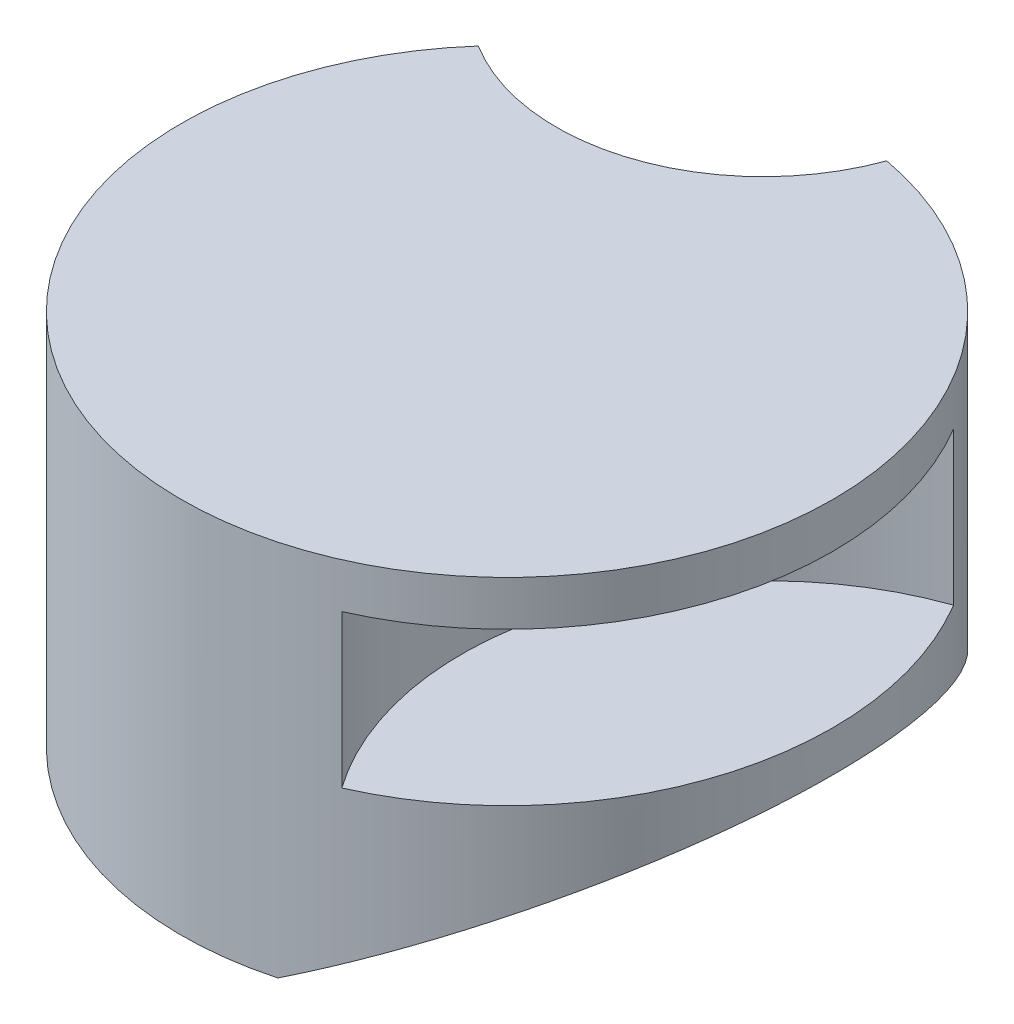
from build123d import *

# Parameters (mm, degrees)
BOSS_EXTRUDE1_DEPTH = 84
CUT_EXTRUDE2_DEPTH  = 34
CUT_EXTRUDE3_DEPTH  = 144.7823905
CUT_EXTRUDE4_DEPTH  = 43


with BuildPart() as part:
    # Sketch1 → Boss-Extrude1 (new body)
    with BuildSketch(Plane(origin=(0, 0, 0), x_dir=(1, 0, 0), z_dir=(0, 1, 0))):
        with BuildLine():
            ThreePointArc((-54.355236912, 47.976642444), (23.634324541, -68.539541168), (13.231432449, 71.2823905))
            ThreePointArc((13.231432449, 71.2823905), (-15.004428567, 43.512842845), (-54.355236912, 47.976642444))
        make_face()
    extrude(amount=BOSS_EXTRUDE1_DEPTH)

    # Sketch3 → Cut-Extrude2 (cut)
    with BuildSketch(Plane(origin=(0, 74, 0), x_dir=(1, 0, 0), z_dir=(0, 1, 0))):
        with BuildLine():
            ThreePointArc((62.290772837, 37.095951523), (20.191041077, -6.413624813), (29.465733324, -66.242135833))
            ThreePointArc((29.465733324, -66.242135833), (69.097787087, -21.948708839), (62.290772837, 37.095951523))
        make_face()
    extrude(amount=-CUT_EXTRUDE2_DEPTH, mode=Mode.SUBTRACT)

    # Sketch9 → Cut-Extrude3 (cut, through all)
    with BuildSketch(Plane.XY.offset(72.5)):
        Polygon((72.5, 30.908380348), (18.965114857, 0), (72.5, 0), align=None)
    extrude(amount=-CUT_EXTRUDE3_DEPTH, mode=Mode.SUBTRACT)

    # Sketch10 → Cut-Extrude4 (cut)
    with BuildSketch(Plane(origin=(0, 63, 0), x_dir=(1, 0, 0), z_dir=(0, 1, 0))):
        Polygon((-3.366442431, -32.270509831), (7.531695489, 1.270509831), (-21, 22), (-49.531695489, 1.270509831), (-38.633557569, -32.270509831), align=None)
    extrude(amount=-CUT_EXTRUDE4_DEPTH, mode=Mode.SUBTRACT)


solid = part.part
